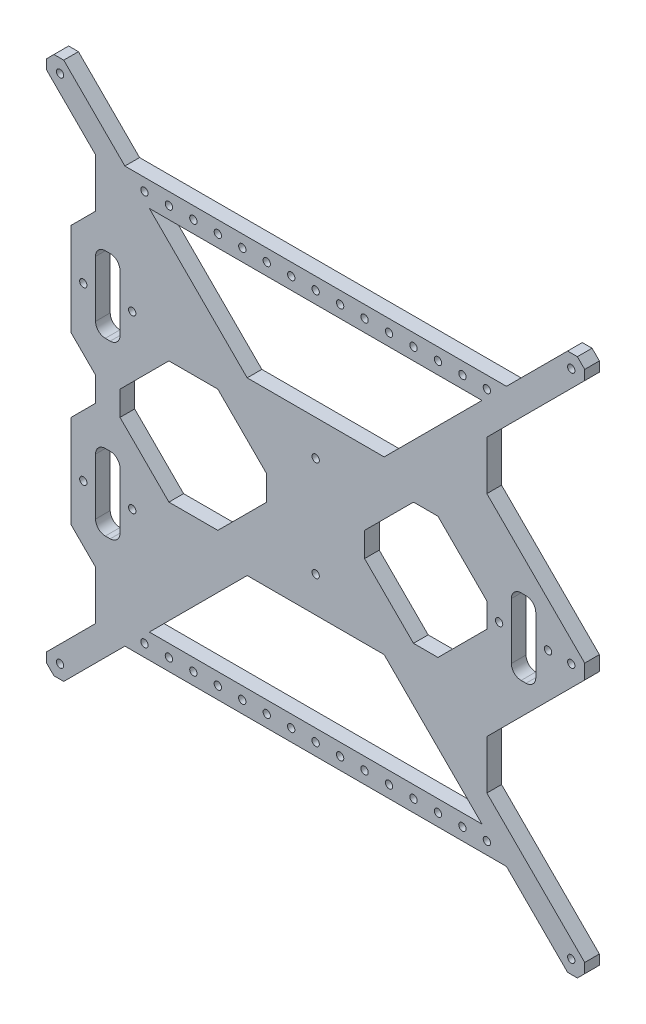
from build123d import *

# Parameters (mm, degrees)
MODEL_R                 = 1.5
SALIENTE_EXTRUIR1_DEPTH = 6
CROQUIS2_R              = 1.5
CROQUIS2_R_2            = 0.241728607
CORTAR_EXTRUIR1_DEPTH   = 7


with BuildPart() as part:
    # Model → Saliente-Extruir1 (new body)
    with BuildSketch(Plane.XY):
        Polygon((-105, 110), (-107, 110), (-110, 107), (-110, 105), (-110, 103), (-90, 83), (-90, 63), (-100, 53), (-100, 15), (-90, 5), (-90, -5), (-100, -15), (-100, -53), (-90, -63), (-90, -83), (-110, -103), (-110, -107), (-107, -110), (-105, -110), (-103, -110), (-78, -85), (78, -85), (103, -110), (105, -110), (107, -110), (110, -107), (110, -103), (90, -83), (70, -63), (70, -43), (90, -23), (110, -3), (110, 3), (90, 23), (70, 43), (70, 63), (110, 103), (110, 106), (110, 107), (107, 110), (103, 110), (80, 87), (78, 85), (-78, 85), (-103, 110), align=None)
        with Locations((104.5, 0)):
            Circle(MODEL_R, mode=Mode.SUBTRACT)
        with Locations((-95, 35)):
            Circle(MODEL_R, mode=Mode.SUBTRACT)
        with Locations((-75, 35)):
            Circle(MODEL_R, mode=Mode.SUBTRACT)
        with Locations((-95, -35)):
            Circle(MODEL_R, mode=Mode.SUBTRACT)
        with Locations((-75, -35)):
            Circle(MODEL_R, mode=Mode.SUBTRACT)
        with Locations((95, 0)):
            Circle(MODEL_R, mode=Mode.SUBTRACT)
        with Locations((75, 0)):
            Circle(MODEL_R, mode=Mode.SUBTRACT)
        with Locations((-104.5, 104.5)):
            Circle(MODEL_R, mode=Mode.SUBTRACT)
        with Locations((104.5, -104.5)):
            Circle(MODEL_R, mode=Mode.SUBTRACT)
        with Locations((104.5, 104.5)):
            Circle(MODEL_R, mode=Mode.SUBTRACT)
        with Locations((-104.5, -104.5)):
            Circle(MODEL_R, mode=Mode.SUBTRACT)
        with Locations((0, -20.5)):
            Circle(MODEL_R, mode=Mode.SUBTRACT)
        with Locations((0, 20.5)):
            Circle(MODEL_R, mode=Mode.SUBTRACT)
        Polygon((40, 47), (38, 45), (28, 35), (-28, 35), (-68, 75), (68, 75), align=None, mode=Mode.SUBTRACT)
        Polygon((28, -35), (-28, -35), (-68, -75), (68, -75), align=None, mode=Mode.SUBTRACT)
        Polygon((-80, 5), (-60, 25), (-40, 25), (-20, 5), (-20, -5), (-40, -25), (-60, -25), (-80, -5), align=None, mode=Mode.SUBTRACT)
        Polygon((50, 25), (70, 5), (70, -5), (50, -25), (40, -25), (20, -5), (20, 5), (40, 25), align=None, mode=Mode.SUBTRACT)
        with BuildLine():
            Line((-90, -46), (-90, -23))
            ThreePointArc((-90, -23), (-88.828427125, -20.171572875), (-86, -19))
            Line((-86, -19), (-84, -19))
            ThreePointArc((-84, -19), (-81.171572875, -20.171572875), (-80, -23))
            Line((-80, -23), (-80, -46))
            ThreePointArc((-80, -46), (-81.171572875, -48.828427125), (-84, -50))
            Line((-84, -50), (-86, -50))
            ThreePointArc((-86, -50), (-88.828427125, -48.828427125), (-90, -46))
        make_face(mode=Mode.SUBTRACT)
        with BuildLine():
            Line((-90, 24.007036896), (-90, 47.007036896))
            ThreePointArc((-90, 47.007036896), (-88.828427125, 49.835464021), (-86, 51.007036896))
            Line((-86, 51.007036896), (-84, 51.007036896))
            ThreePointArc((-84, 51.007036896), (-81.171572875, 49.835464021), (-80, 47.007036896))
            Line((-80, 47.007036896), (-80, 24.007036896))
            ThreePointArc((-80, 24.007036896), (-81.171572875, 21.178609771), (-84, 20.007036896))
            Line((-84, 20.007036896), (-86, 20.007036896))
            ThreePointArc((-86, 20.007036896), (-88.828427125, 21.178609771), (-90, 24.007036896))
        make_face(mode=Mode.SUBTRACT)
        with BuildLine():
            Line((80, -12.137123607), (80, 10.862876393))
            ThreePointArc((80, 10.862876393), (81.171572875, 13.691303518), (84, 14.862876393))
            Line((84, 14.862876393), (86, 14.862876393))
            ThreePointArc((86, 14.862876393), (88.828427125, 13.691303518), (90, 10.862876393))
            Line((90, 10.862876393), (90, -12.137123607))
            ThreePointArc((90, -12.137123607), (88.828427125, -14.965550732), (86, -16.137123607))
            Line((86, -16.137123607), (84, -16.137123607))
            ThreePointArc((84, -16.137123607), (81.171572875, -14.965550732), (80, -12.137123607))
        make_face(mode=Mode.SUBTRACT)
    extrude(amount=SALIENTE_EXTRUIR1_DEPTH)

    # Croquis2 → Cortar-Extruir1 (cut, through all)
    with BuildSketch(Plane(origin=(0, 0, 0), x_dir=(-1, 0, 0), z_dir=(0, 0, -1))):
        with Locations((-70, 80)):
            Circle(CROQUIS2_R)
        with Locations((-70, -80)):
            Circle(CROQUIS2_R)
        with Locations((-61.506705716, -90.733837273)):
            Circle(CROQUIS2_R_2)
        with Locations((-60, -80)):
            Circle(CROQUIS2_R)
        with Locations((-60, 80)):
            Circle(CROQUIS2_R)
        with Locations((-50, -80)):
            Circle(CROQUIS2_R)
        with Locations((-50, 80)):
            Circle(CROQUIS2_R)
        with Locations((-40, -80)):
            Circle(CROQUIS2_R)
        with Locations((-40, 80)):
            Circle(CROQUIS2_R)
        with Locations((-30, -80)):
            Circle(CROQUIS2_R)
        with Locations((-30, 80)):
            Circle(CROQUIS2_R)
        with Locations((-20, -80)):
            Circle(CROQUIS2_R)
        with Locations((-20, 80)):
            Circle(CROQUIS2_R)
        with Locations((-10, -80)):
            Circle(CROQUIS2_R)
        with Locations((-10, 80)):
            Circle(CROQUIS2_R)
        with Locations((0, -80)):
            Circle(CROQUIS2_R)
        with Locations((0, 80)):
            Circle(CROQUIS2_R)
        with Locations((10, -80)):
            Circle(CROQUIS2_R)
        with Locations((10, 80)):
            Circle(CROQUIS2_R)
        with Locations((20, -80)):
            Circle(CROQUIS2_R)
        with Locations((20, 80)):
            Circle(CROQUIS2_R)
        with Locations((30, -80)):
            Circle(CROQUIS2_R)
        with Locations((30, 80)):
            Circle(CROQUIS2_R)
        with Locations((40, -80)):
            Circle(CROQUIS2_R)
        with Locations((40, 80)):
            Circle(CROQUIS2_R)
        with Locations((50, -80)):
            Circle(CROQUIS2_R)
        with Locations((50, 80)):
            Circle(CROQUIS2_R)
        with Locations((60, -80)):
            Circle(CROQUIS2_R)
        with Locations((60, 80)):
            Circle(CROQUIS2_R)
        with Locations((70, -80)):
            Circle(CROQUIS2_R)
        with Locations((70, 80)):
            Circle(CROQUIS2_R)
    extrude(amount=-CORTAR_EXTRUIR1_DEPTH, mode=Mode.SUBTRACT)


solid = part.part
